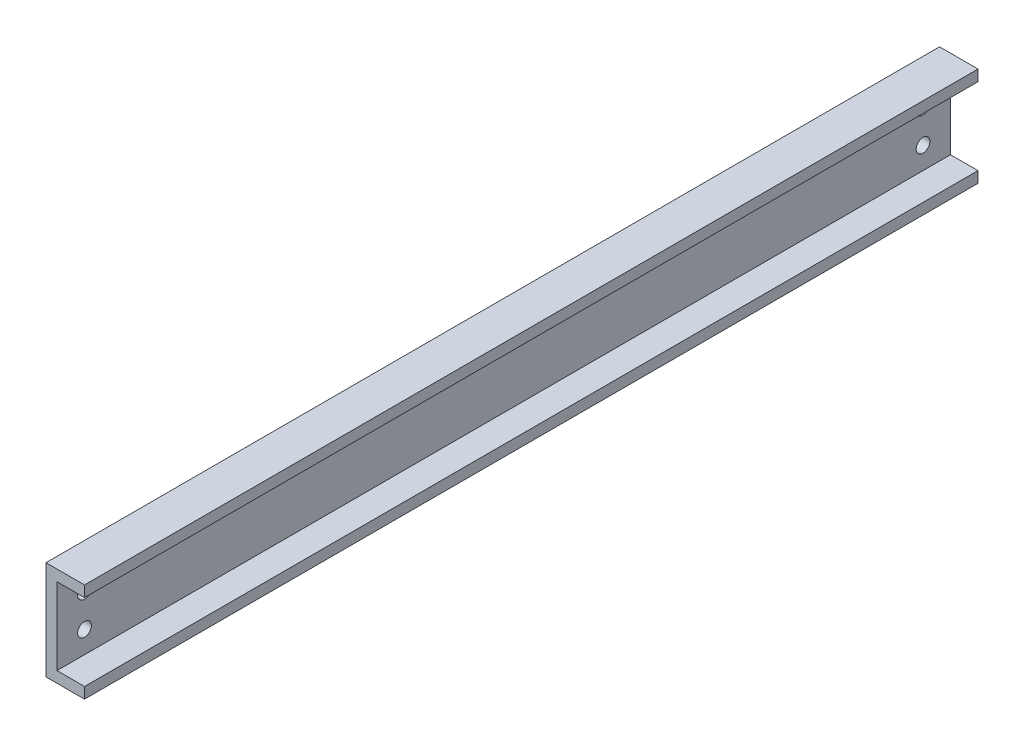
from build123d import *

# Parameters (mm, degrees)
BOSS_EXTRUDE1_DEPTH = 162.5
SKETCH2_R           = 1.25
CUT_EXTRUDE1_DEPTH  = 8


with BuildPart() as part:
    # Sketch1 → Boss-Extrude1 (new body)
    with BuildSketch(Plane.XY):
        Polygon((0, 9), (0, -9), (7, -9), (7, -7), (2, -7), (2, 7), (7, 7), (7, 9), align=None)
    extrude(amount=-BOSS_EXTRUDE1_DEPTH)

    # Sketch2 → Cut-Extrude1 (cut, through all)
    with BuildSketch(Plane.ZY):
        with Locations((-5, 3)):
            Circle(SKETCH2_R)
        with Locations((-5, -3)):
            Circle(SKETCH2_R)
        with Locations((-157.5, -3)):
            Circle(SKETCH2_R)
        with Locations((-157.5, 3)):
            Circle(SKETCH2_R)
    extrude(amount=-CUT_EXTRUDE1_DEPTH, mode=Mode.SUBTRACT)


solid = part.part
